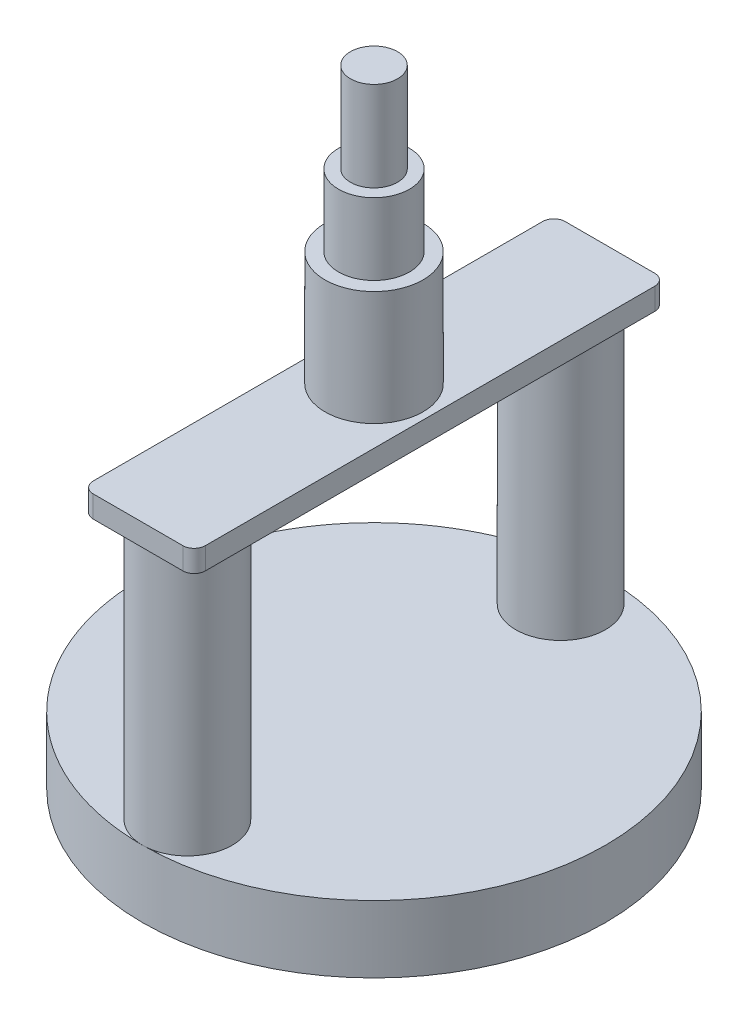
from build123d import *

# Parameters (mm, degrees)
SKETCH1_R           = 20.65
BOSS_EXTRUDE1_DEPTH = 5.98
SKETCH2_R           = 4
BOSS_EXTRUDE2_DEPTH = 23.4
BOSS_EXTRUDE3_DEPTH = 1.95
SKETCH4_R           = 4.375
BOSS_EXTRUDE4_DEPTH = 10.2
SKETCH5_R           = 3.165
BOSS_EXTRUDE5_DEPTH = 6.4
SKETCH6_R           = 2.1
BOSS_EXTRUDE6_DEPTH = 8


with BuildPart() as part:
    # Sketch1 → Boss-Extrude1 (new body)
    with BuildSketch(Plane(origin=(0, 0, 0), x_dir=(1, 0, 0), z_dir=(0, 1, 0))):
        Circle(SKETCH1_R)
    extrude(amount=BOSS_EXTRUDE1_DEPTH)

    # Sketch2 → Boss-Extrude2 (add)
    with BuildSketch(Plane(origin=(0, 5.98, 0), x_dir=(1, 0, 0), z_dir=(0, 1, 0))):
        with Locations((0, -16.65)):
            Circle(SKETCH2_R)
        with Locations((0, 16.65)):
            Circle(SKETCH2_R)
    extrude(amount=BOSS_EXTRUDE2_DEPTH)

    # Sketch3 → Boss-Extrude3 (add)
    with BuildSketch(Plane(origin=(0, 29.38, 0), x_dir=(1, 0, 0), z_dir=(0, 1, 0))):
        with BuildLine():
            Line((-4, -21.05), (4, -21.05))
            ThreePointArc((4, -21.05), (4.707106781, -20.757106781), (5, -20.05))
            Line((5, -20.05), (5, 20.05))
            ThreePointArc((5, 20.05), (4.707106781, 20.757106781), (4, 21.05))
            Line((4, 21.05), (-4, 21.05))
            ThreePointArc((-4, 21.05), (-4.707106781, 20.757106781), (-5, 20.05))
            Line((-5, 20.05), (-5, -20.05))
            ThreePointArc((-5, -20.05), (-4.707106781, -20.757106781), (-4, -21.05))
        make_face()
    extrude(amount=BOSS_EXTRUDE3_DEPTH)

    # Sketch4 → Boss-Extrude4 (add)
    with BuildSketch(Plane(origin=(0, 31.33, 0), x_dir=(1, 0, 0), z_dir=(0, 1, 0))):
        Circle(SKETCH4_R)
    extrude(amount=BOSS_EXTRUDE4_DEPTH)

    # Sketch5 → Boss-Extrude5 (add)
    with BuildSketch(Plane(origin=(0, 41.53, 0), x_dir=(1, 0, 0), z_dir=(0, 1, 0))):
        Circle(SKETCH5_R)
    extrude(amount=BOSS_EXTRUDE5_DEPTH)

    # Sketch6 → Boss-Extrude6 (add)
    with BuildSketch(Plane(origin=(0, 47.93, 0), x_dir=(1, 0, 0), z_dir=(0, 1, 0))):
        Circle(SKETCH6_R)
    extrude(amount=BOSS_EXTRUDE6_DEPTH)


solid = part.part
